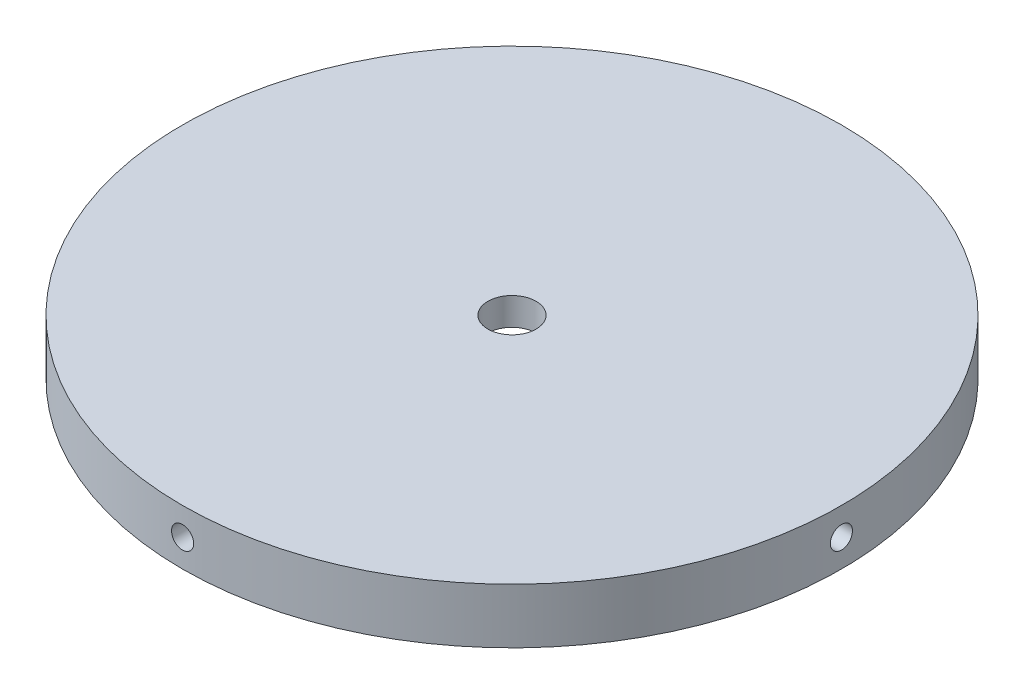
from build123d import *

# Parameters (mm, degrees)
SKETCH2_R               = 75.946
BOSS_EXTRUDE1_DEPTH     = 12.7
SKETCH3_R               = 5.55625
CUT_EXTRUDE1_DEPTH      = 1
CUT_EXTRUDE1_DEPTH_BACK = 13.7
CIRPATTERN2_COUNT       = 4
CIRPATTERN2_ANGLE       = 270
SKETCH11_R              = 69.596
CUT_EXTRUDE2_DEPTH      = 6.35


with BuildPart() as part:
    # Sketch2 → Boss-Extrude1 (new body)
    with BuildSketch(Plane(origin=(0, 0, 0), x_dir=(1, 0, 0), z_dir=(0, 1, 0))):
        Circle(SKETCH2_R)
    extrude(amount=BOSS_EXTRUDE1_DEPTH)

    # Sketch3 → Cut-Extrude1 (cut, two sides)
    with BuildSketch(Plane(origin=(0, 12.7, 0), x_dir=(1, 0, 0), z_dir=(0, 1, 0))) as cut_extrude1_sk:
        Circle(SKETCH3_R)
    extrude(amount=CUT_EXTRUDE1_DEPTH, mode=Mode.SUBTRACT)
    extrude(cut_extrude1_sk.sketch, amount=-CUT_EXTRUDE1_DEPTH_BACK, mode=Mode.SUBTRACT)

    # Sketch10 → 1_4-20 Tapped Hole1 (revolve, cut)
    with BuildSketch(Plane(origin=(-76.1746, 6.35, 0), x_dir=(0, 0, 1), z_dir=(0, 1, 0))):
        Polygon((0, 0), (0, 26.933816902), (2.5527, 25.4), (2.5527, 0), align=None)
    f_1_4_20_tapped_hole1 = revolve(axis=Axis((-82.5246, 6.35, 0), (1, 0, 0)), mode=Mode.SUBTRACT)

    # CirPattern2: 1_4-20 Tapped Hole1 ×4 about axis
    cirpattern2_axis = Axis((0, 12.7, 0), (0, -1, 0))
    for i in range(1, CIRPATTERN2_COUNT):
        add(f_1_4_20_tapped_hole1.rotate(cirpattern2_axis, i * CIRPATTERN2_ANGLE / (CIRPATTERN2_COUNT - 1)), mode=Mode.SUBTRACT)

    # Sketch11 → Cut-Extrude2 (cut)
    with BuildSketch(Plane.XZ):
        Circle(SKETCH11_R)
    extrude(amount=-CUT_EXTRUDE2_DEPTH, mode=Mode.SUBTRACT)


solid = part.part
